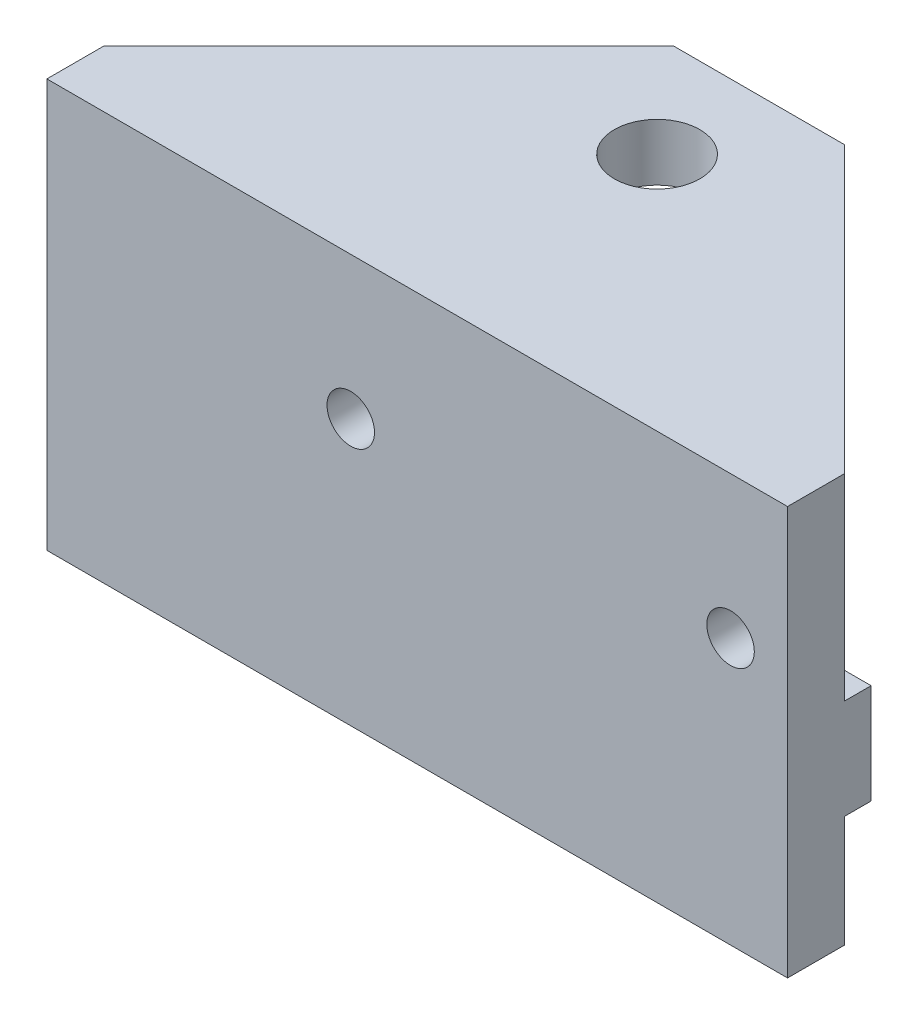
from build123d import *

# Parameters (mm, degrees)
ESQUISSE1_W                                   = 39
ESQUISSE1_H                                   = 18.5
BOSS_EXTRU_1_DEPTH                            = 3
ESQUISSE4_W                                   = 1.4
ESQUISSE4_H                                   = 5.26
BOSS_EXTRU_2_DEPTH                            = 39
TROU_POUR_TARAUDAGE_POUR_TROU_TARAUD_M3_D     = 2.5
TROU_POUR_TARAUDAGE_POUR_TROU_TARAUD_M3_DEPTH = 16
ESQUISSE7_W                                   = 39
ESQUISSE7_H                                   = 18
BOSS_EXTRU_3_DEPTH                            = 3
CHANFREIN1_SIZE                               = 15
D_GAGEMENT_M42_D                              = 4.5
D_GAGEMENT_M42_DEPTH                          = 16


with BuildPart() as part:
    # Esquisse1 → Boss.-Extru.1 (new body)
    with BuildSketch(Plane.XY):
        with Locations((235.738481082, -2.221059771)):
            Rectangle(ESQUISSE1_W, ESQUISSE1_H)
    extrude(amount=BOSS_EXTRU_1_DEPTH)

    # Esquisse4 → Boss.-Extru.2 (add)
    with BuildSketch(Plane(origin=(255.238481082, 0, 0), x_dir=(0, 0, -1), z_dir=(1, 0, 0))):
        with Locations((0.7, -2.971059771)):
            Rectangle(ESQUISSE4_W, ESQUISSE4_H)
    extrude(amount=-BOSS_EXTRU_2_DEPTH)

    # Trou pour taraudage pour trou taraudé M31
    with Locations(Plane.XY.offset(3)):
        with Locations((232.238481082, 2.528940229), (252.238481082, 2.528940229)):
            Hole(TROU_POUR_TARAUDAGE_POUR_TROU_TARAUD_M3_D / 2, depth=TROU_POUR_TARAUDAGE_POUR_TROU_TARAUD_M3_DEPTH)

    # Esquisse7 → Boss.-Extru.3 (add)
    with BuildSketch(Plane(origin=(0, 7.028940229, 0), x_dir=(1, 0, 0), z_dir=(0, 1, 0))):
        with Locations((235.738481082, 6)):
            Rectangle(ESQUISSE7_W, ESQUISSE7_H)
    extrude(amount=BOSS_EXTRU_3_DEPTH)

    # Chanfrein1
    chanfrein1_edges = [part.edges().sort_by_distance(p)[0] for p in [
        (216.238481082, 8.528940229, -15),
        (255.238481082, 8.528940229, -15),
    ]]
    chamfer(chanfrein1_edges, length=CHANFREIN1_SIZE)

    # Dégagement M42
    with Locations(Plane(origin=(0, 10.028940229, 0), x_dir=(1, 0, 0), z_dir=(0, 1, 0))):
        with Locations((235.738481082, 9.63)):
            Hole(D_GAGEMENT_M42_D / 2, depth=D_GAGEMENT_M42_DEPTH)


solid = part.part
